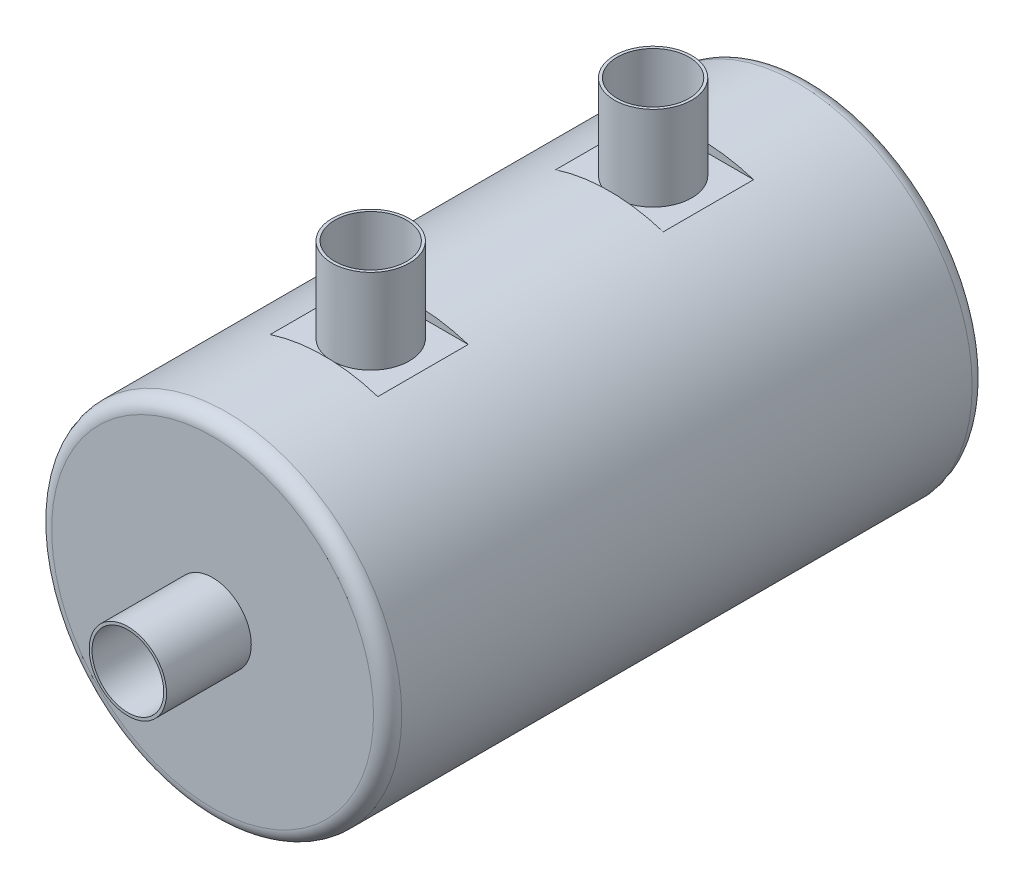
from build123d import *

# Parameters (mm, degrees)
SKETCH2_R               = 31
SKETCH2_R_2             = 28
BOSS_EXTRUDE1_DEPTH     = 100
BOSS_EXTRUDE2_START     = 3
SKETCH3_R               = 31
BOSS_EXTRUDE2_DEPTH     = 3
SKETCH4_R               = 31
BOSS_EXTRUDE3_DEPTH     = 3
CUT_EXTRUDE1_DEPTH      = 112.941949242
CUT_EXTRUDE1_DEPTH_BACK = 112.941949242
SKETCH5_W               = 16
SKETCH5_H               = 1.5
SKETCH6_R               = 6.85
SKETCH6_R_2             = 6.35
BOSS_EXTRUDE4_DEPTH     = 15
CUT_EXTRUDE2_START      = -15
SKETCH6_2_R             = 6.35
CUT_EXTRUDE2_DEPTH      = 15
SKETCH7_R               = 6.85
SKETCH7_R_2             = 6.35
BOSS_EXTRUDE5_DEPTH     = 15
CUT_EXTRUDE3_START      = -15
SKETCH7_2_R             = 6.35
CUT_EXTRUDE3_DEPTH      = 15
FILLET1_R               = 2.5


with BuildPart() as part:
    # Sketch2 → Boss-Extrude1 (new body)
    with BuildSketch(Plane.XY):
        Circle(SKETCH2_R)
        Circle(SKETCH2_R_2, mode=Mode.SUBTRACT)
    extrude(amount=-BOSS_EXTRUDE1_DEPTH)

    # Sketch3 → Boss-Extrude2 (add)
    with BuildSketch(Plane.XY.offset(BOSS_EXTRUDE2_START)):
        Circle(SKETCH3_R)
    extrude(amount=-BOSS_EXTRUDE2_DEPTH)

    # Sketch4 → Boss-Extrude3 (add)
    with BuildSketch(Plane(origin=(0, 0, -100), x_dir=(-1, 0, 0), z_dir=(0, 0, -1))):
        Circle(SKETCH4_R)
    extrude(amount=BOSS_EXTRUDE3_DEPTH)

    # Sketch5 → Cut-Extrude1 (cut, two sides: drawn at the far end of the back side and taken through both)
    with BuildSketch(Plane(origin=(0, 0, 0), x_dir=(0, 0, -1), z_dir=(1, 0, 0)).offset(-CUT_EXTRUDE1_DEPTH_BACK)):
        with Locations((75.269911272, 30.25)):
            Rectangle(SKETCH5_W, SKETCH5_H)
        with Locations((24.730088728, 30.25)):
            Rectangle(SKETCH5_W, SKETCH5_H)
    extrude(amount=CUT_EXTRUDE1_DEPTH + CUT_EXTRUDE1_DEPTH_BACK, mode=Mode.SUBTRACT)

    # Sketch6 → Boss-Extrude4 (add)
    # profile 1 of 2: a face of its own
    with BuildSketch(Plane(origin=(0, 29.5, 0), x_dir=(1, 0, 0), z_dir=(0, 1, 0))):
        with Locations((0, 25)):
            Circle(SKETCH6_R)
        with Locations((0, 25)):
            Circle(SKETCH6_R_2, mode=Mode.SUBTRACT)
    # profile 2 of 2: a face of its own
    with BuildSketch(Plane(origin=(0, 29.5, 0), x_dir=(1, 0, 0), z_dir=(0, 1, 0))):
        with Locations((0, 75)):
            Circle(SKETCH6_R)
        with Locations((0, 75)):
            Circle(SKETCH6_R_2, mode=Mode.SUBTRACT)
    extrude(amount=BOSS_EXTRUDE4_DEPTH)

    # Sketch6_2 → Cut-Extrude2 (cut)
    with BuildSketch(Plane(origin=(0, 29.5, 0), x_dir=(1, 0, 0), z_dir=(0, 1, 0)).offset(CUT_EXTRUDE2_START)):
        with Locations((0, 25)):
            Circle(SKETCH6_2_R)
        with Locations((0, 75)):
            Circle(SKETCH6_2_R)
    extrude(amount=CUT_EXTRUDE2_DEPTH, mode=Mode.SUBTRACT)

    # Sketch7 → Boss-Extrude5 (add)
    with BuildSketch(Plane.XY.offset(3)):
        Circle(SKETCH7_R)
        Circle(SKETCH7_R_2, mode=Mode.SUBTRACT)
    boss_extrude5 = extrude(amount=BOSS_EXTRUDE5_DEPTH)

    # Sketch7_2 → Cut-Extrude3 (cut)
    with BuildSketch(Plane.XY.offset(3).offset(CUT_EXTRUDE3_START)):
        Circle(SKETCH7_2_R)
    cut_extrude3 = extrude(amount=CUT_EXTRUDE3_DEPTH, mode=Mode.SUBTRACT)

    # Mirror2: Boss-Extrude5, Cut-Extrude3 across plane
    add(boss_extrude5.mirror(Plane.XY.offset(-50)))
    add(cut_extrude3.mirror(Plane.XY.offset(-50)), mode=Mode.SUBTRACT)

    # Fillet1
    fillet1_edges = [part.edges().sort_by_distance(p)[0] for p in [
        (31, 0, -103),
        (-31, 0, 3),
    ]]
    fillet(fillet1_edges, radius=FILLET1_R)


solid = part.part
